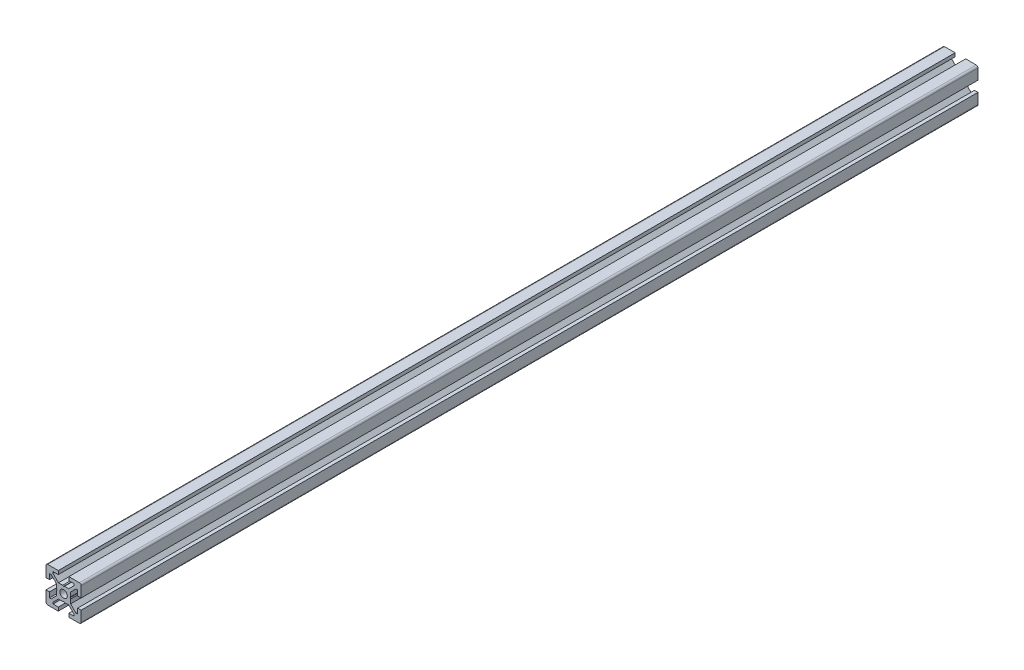
from build123d import *

# Parameters (mm, degrees)
EXTRUDE_1_DEPTH = 510
SKETCH_2_W      = 260
SKETCH_2_H      = 2.1


with BuildPart() as part:
    # ｽｹｯﾁ1 → ﾎﾞｽ - 押し出し1 (new body)
    with BuildSketch(Plane.XY):
        with BuildLine():
            Line((-10, -3), (-10, -9))
            ThreePointArc((-10, -9), (-9.707106781, -9.707106781), (-9, -10))
            Line((-9, -10), (-3, -10))
            Line((-3, -10), (-3, -8))
            Line((-3, -8), (-6, -8))
            Line((-6, -8), (-6, -7.060660172))
            Line((-6, -7.060660172), (-2.939339828, -4))
            Line((-2.939339828, -4), (-0.519615242, -4))
            Line((-0.519615242, -4), (0, -3.7))
            Line((0, -3.7), (0.519615242, -4))
            Line((0.519615242, -4), (2.939339828, -4))
            Line((2.939339828, -4), (6, -7.060660172))
            Line((6, -7.060660172), (6, -8))
            Line((6, -8), (3, -8))
            Line((3, -8), (3, -10))
            Line((3, -10), (9, -10))
            ThreePointArc((9, -10), (9.707106781, -9.707106781), (10, -9))
            Line((10, -9), (10, -3))
            Line((10, -3), (8, -3))
            Line((8, -3), (8, -6))
            Line((8, -6), (7.060660172, -6))
            Line((7.060660172, -6), (4, -2.939339828))
            Line((4, -2.939339828), (4, -0.519615242))
            Line((4, -0.519615242), (3.7, 0))
            Line((3.7, 0), (4, 0.519615242))
            Line((4, 0.519615242), (4, 2.939339828))
            Line((4, 2.939339828), (7.060660172, 6))
            Line((7.060660172, 6), (8, 6))
            Line((8, 6), (8, 3))
            Line((8, 3), (10, 3))
            Line((10, 3), (10, 9))
            ThreePointArc((10, 9), (9.707106781, 9.707106781), (9, 10))
            Line((9, 10), (3, 10))
            Line((3, 10), (3, 8))
            Line((3, 8), (6, 8))
            Line((6, 8), (6, 7.060660172))
            Line((6, 7.060660172), (2.939339828, 4))
            Line((2.939339828, 4), (0.519615242, 4))
            Line((0.519615242, 4), (0, 3.7))
            Line((0, 3.7), (-0.519615242, 4))
            Line((-0.519615242, 4), (-2.939339828, 4))
            Line((-2.939339828, 4), (-6, 7.060660172))
            Line((-6, 7.060660172), (-6, 8))
            Line((-6, 8), (-3, 8))
            Line((-3, 8), (-3, 10))
            Line((-3, 10), (-9, 10))
            ThreePointArc((-9, 10), (-9.707106781, 9.707106781), (-10, 9))
            Line((-10, 9), (-10, 3))
            Line((-10, 3), (-8, 3))
            Line((-8, 3), (-8, 6))
            Line((-8, 6), (-7.060660172, 6))
            Line((-7.060660172, 6), (-4, 2.939339828))
            Line((-4, 2.939339828), (-4, 0.519615242))
            Line((-4, 0.519615242), (-3.7, 0))
            Line((-3.7, 0), (-4, -0.519615242))
            Line((-4, -0.519615242), (-4, -2.939339828))
            Line((-4, -2.939339828), (-7.060660172, -6))
            Line((-7.060660172, -6), (-8, -6))
            Line((-8, -6), (-8, -3))
            Line((-8, -3), (-10, -3))
        make_face()
    extrude(amount=-EXTRUDE_1_DEPTH)

    # ｽｹｯﾁ2 → ｶｯﾄ - 回転1 (revolve, cut)
    with BuildSketch(Plane(origin=(0, 0, 0), x_dir=(0, 0, -1), z_dir=(1, 0, 0))):
        with Locations((130, 1.05)):
            Rectangle(SKETCH_2_W, SKETCH_2_H)
    revolve(axis=Axis((0, 0, -260), (0, 0, 1)), mode=Mode.SUBTRACT)


solid = part.part
